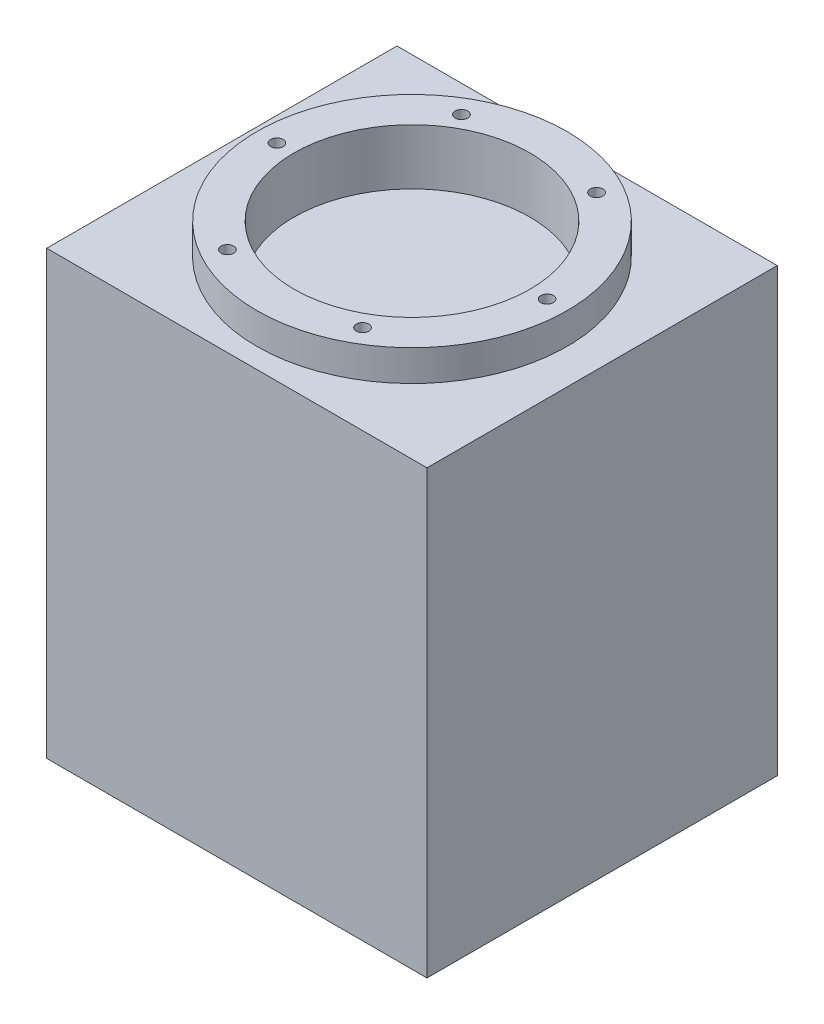
from build123d import *

# Parameters (mm, degrees)
SKETCH1_W           = 76
SKETCH1_H           = 70
BOSS_EXTRUDE1_DEPTH = 88.3
SKETCH2_R           = 31
BOSS_EXTRUDE2_DEPTH = 6.2
CIRPATTERN1_COUNT   = 6
SKETCH8_R           = 23.588802374
CUT_EXTRUDE1_DEPTH  = 11.11


with BuildPart() as part:
    # Sketch1 → Boss-Extrude1 (new body)
    with BuildSketch(Plane(origin=(0, 0, 0), x_dir=(1, 0, 0), z_dir=(0, 1, 0))):
        Rectangle(SKETCH1_W, SKETCH1_H)
    extrude(amount=BOSS_EXTRUDE1_DEPTH)

    # Sketch2 → Boss-Extrude2 (add)
    with BuildSketch(Plane(origin=(0, 88.3, 0), x_dir=(1, 0, 0), z_dir=(0, 1, 0))):
        Circle(SKETCH2_R)
    extrude(amount=BOSS_EXTRUDE2_DEPTH)

    # Sketch7 → M3x0.5 Tapped Hole3 (revolve, cut)
    with BuildSketch(Plane(origin=(27, 94.5, 0), x_dir=(0, 0, 1), z_dir=(1, 0, 0))):
        Polygon((0, 0), (0, 7.251075774), (1.25, 6.5), (1.25, 0), align=None)
    m3x0_5_tapped_hole3 = revolve(axis=Axis((27, 100.85, 0), (0, -1, 0)), mode=Mode.SUBTRACT)

    # CirPattern1: M3x0.5 Tapped Hole3 ×6 about axis
    cirpattern1_axis = Axis((0, 112.582788709, 0), (0, -1, 0))
    for i in range(1, CIRPATTERN1_COUNT):
        add(m3x0_5_tapped_hole3.rotate(cirpattern1_axis, i * 360 / CIRPATTERN1_COUNT), mode=Mode.SUBTRACT)

    # Sketch8 → Cut-Extrude1 (cut)
    with BuildSketch(Plane(origin=(0, 94.5, 0), x_dir=(1, 0, 0), z_dir=(0, 1, 0))):
        Circle(SKETCH8_R)
    extrude(amount=-CUT_EXTRUDE1_DEPTH, mode=Mode.SUBTRACT)


solid = part.part
